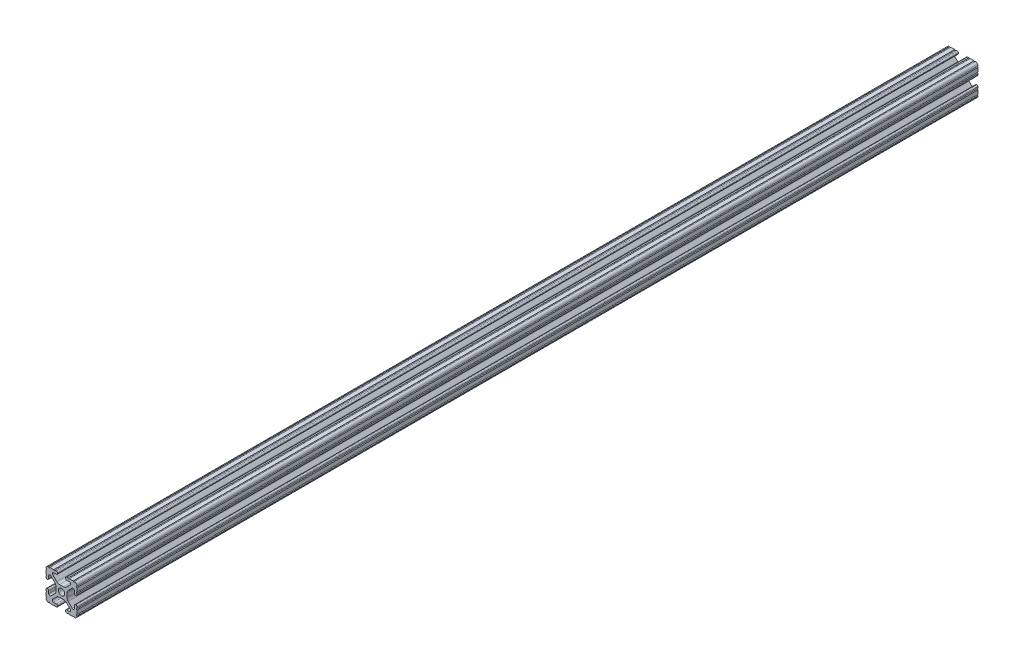
from build123d import *

# Parameters (mm, degrees)
SKETCH1_R           = 2.6035
BOSS_EXTRUDE1_DEPTH = 368.3


with BuildPart() as part:
    # Sketch1 → Boss-Extrude1 (new body, symmetric)
    with BuildSketch(Plane.XY):
        with BuildLine():
            Line((-7.179650497, -8.645192506), (-3.952270251, -5.423690499))
            ThreePointArc((-3.952270251, -5.423690499), (-2.922936451, -4.736929036), (-1.709253557, -4.4958))
            Line((-1.709253557, -4.4958), (1.709253557, -4.4958))
            ThreePointArc((1.709253557, -4.4958), (2.922936451, -4.736929036), (3.952270251, -5.423690499))
            Line((3.952270251, -5.423690499), (7.179650497, -8.645192506))
            ThreePointArc((7.179650497, -8.645192506), (7.41473083, -9.822813117), (6.416408329, -10.4902))
            Line((6.416408329, -10.4902), (4.287512407, -10.4902))
            ThreePointArc((4.287512407, -10.4902), (3.54574862, -10.79744862), (3.2385, -11.539212407))
            Line((3.2385, -11.539212407), (3.2385, -11.650987593))
            ThreePointArc((3.2385, -11.650987593), (3.54574862, -12.39275138), (4.287512407, -12.7))
            Line((4.287512407, -12.7), (5.317126718, -12.7))
            ThreePointArc((5.317126718, -12.7), (5.825126718, -12.192), (6.333126718, -12.7))
            Line((6.333126718, -12.7), (9.550443118, -12.7))
            ThreePointArc((9.550443118, -12.7), (10.058366869, -12.192000006), (10.566443095, -12.699847501))
            ThreePointArc((10.566443095, -12.699847501), (12.082537762, -12.08250727), (12.699846982, -10.566399977))
            ThreePointArc((12.699846982, -10.566399977), (12.192000006, -10.058323491), (12.7, -9.5504))
            Line((12.7, -9.5504), (12.7, -6.3330836))
            ThreePointArc((12.7, -6.3330836), (12.192, -5.8250836), (12.7, -5.3170836))
            Line((12.7, -5.3170836), (12.7, -4.287469289))
            ThreePointArc((12.7, -4.287469289), (12.39275138, -3.545705502), (11.650987593, -3.238456882))
            Line((11.650987593, -3.238456882), (11.539212407, -3.238456882))
            ThreePointArc((11.539212407, -3.238456882), (10.79744862, -3.545705502), (10.4902, -4.287469289))
            Line((10.4902, -4.287469289), (10.4902, -6.402089023))
            ThreePointArc((10.4902, -6.402089023), (9.856505071, -7.351067942), (8.737131347, -7.129408934))
            Line((8.737131347, -7.129408934), (5.441005833, -3.840816462))
            ThreePointArc((5.441005833, -3.840816462), (4.750877967, -2.809883091), (4.5085, -1.593185507))
            Line((4.5085, -1.593185507), (4.5085, 1.593185507))
            ThreePointArc((4.5085, 1.593185507), (4.750877967, 2.809883091), (5.441005833, 3.840816462))
            Line((5.441005833, 3.840816462), (8.737131347, 7.129408934))
            ThreePointArc((8.737131347, 7.129408934), (9.856505071, 7.351067942), (10.4902, 6.402089023))
            Line((10.4902, 6.402089023), (10.4902, 4.287469289))
            ThreePointArc((10.4902, 4.287469289), (10.79744862, 3.545705502), (11.539212407, 3.238456882))
            Line((11.539212407, 3.238456882), (11.650987593, 3.238456882))
            ThreePointArc((11.650987593, 3.238456882), (12.39275138, 3.545705502), (12.7, 4.287469289))
            Line((12.7, 4.287469289), (12.7, 5.3170836))
            ThreePointArc((12.7, 5.3170836), (12.192, 5.8250836), (12.7, 6.3330836))
            Line((12.7, 6.3330836), (12.7, 9.5504))
            ThreePointArc((12.7, 9.5504), (12.192000006, 10.058323491), (12.699846982, 10.566399977))
            ThreePointArc((12.699846982, 10.566399977), (12.082537762, 12.08250727), (10.566443095, 12.699847501))
            ThreePointArc((10.566443095, 12.699847501), (10.058366869, 12.192000006), (9.550443118, 12.7))
            Line((9.550443118, 12.7), (6.333126718, 12.7))
            ThreePointArc((6.333126718, 12.7), (5.825126718, 12.192), (5.317126718, 12.7))
            Line((5.317126718, 12.7), (4.287512407, 12.7))
            ThreePointArc((4.287512407, 12.7), (3.54574862, 12.39275138), (3.2385, 11.650987593))
            Line((3.2385, 11.650987593), (3.2385, 11.539212407))
            ThreePointArc((3.2385, 11.539212407), (3.54574862, 10.79744862), (4.287512407, 10.4902))
            Line((4.287512407, 10.4902), (6.476788598, 10.4902))
            ThreePointArc((6.476788598, 10.4902), (7.432222385, 9.85140422), (7.207036008, 8.724370562))
            Line((7.207036008, 8.724370562), (3.898272566, 5.423169045))
            ThreePointArc((3.898272566, 5.423169045), (2.869120213, 4.736787962), (1.655778399, 4.4958))
            Line((1.655778399, 4.4958), (-1.655778399, 4.4958))
            ThreePointArc((-1.655778399, 4.4958), (-2.869120213, 4.736787962), (-3.898272566, 5.423169045))
            Line((-3.898272566, 5.423169045), (-7.207036008, 8.724370562))
            ThreePointArc((-7.207036008, 8.724370562), (-7.432222385, 9.85140422), (-6.476788598, 10.4902))
            Line((-6.476788598, 10.4902), (-4.287512407, 10.4902))
            ThreePointArc((-4.287512407, 10.4902), (-3.54574862, 10.79744862), (-3.2385, 11.539212407))
            Line((-3.2385, 11.539212407), (-3.2385, 11.650987593))
            ThreePointArc((-3.2385, 11.650987593), (-3.54574862, 12.39275138), (-4.287512407, 12.7))
            Line((-4.287512407, 12.7), (-5.317126718, 12.7))
            ThreePointArc((-5.317126718, 12.7), (-5.825126718, 12.192), (-6.333126718, 12.7))
            Line((-6.333126718, 12.7), (-9.550443118, 12.7))
            ThreePointArc((-9.550443118, 12.7), (-10.058366869, 12.192000006), (-10.566443095, 12.699847501))
            ThreePointArc((-10.566443095, 12.699847501), (-12.082537762, 12.08250727), (-12.699846982, 10.566399977))
            ThreePointArc((-12.699846982, 10.566399977), (-12.192000006, 10.058323491), (-12.7, 9.5504))
            Line((-12.7, 9.5504), (-12.7, 6.3330836))
            ThreePointArc((-12.7, 6.3330836), (-12.192, 5.8250836), (-12.7, 5.3170836))
            Line((-12.7, 5.3170836), (-12.7, 4.287469289))
            ThreePointArc((-12.7, 4.287469289), (-12.39275138, 3.545705502), (-11.650987593, 3.238456882))
            Line((-11.650987593, 3.238456882), (-11.539212407, 3.238456882))
            ThreePointArc((-11.539212407, 3.238456882), (-10.79744862, 3.545705502), (-10.4902, 4.287469289))
            Line((-10.4902, 4.287469289), (-10.4902, 6.402089023))
            ThreePointArc((-10.4902, 6.402089023), (-9.856505071, 7.351067942), (-8.737131347, 7.129408934))
            Line((-8.737131347, 7.129408934), (-5.441005833, 3.840816462))
            ThreePointArc((-5.441005833, 3.840816462), (-4.750877967, 2.809883091), (-4.5085, 1.593185507))
            Line((-4.5085, 1.593185507), (-4.5085, -1.593185507))
            ThreePointArc((-4.5085, -1.593185507), (-4.750877967, -2.809883091), (-5.441005833, -3.840816462))
            Line((-5.441005833, -3.840816462), (-8.737131347, -7.129408934))
            ThreePointArc((-8.737131347, -7.129408934), (-9.856505071, -7.351067942), (-10.4902, -6.402089023))
            Line((-10.4902, -6.402089023), (-10.4902, -4.287469289))
            ThreePointArc((-10.4902, -4.287469289), (-10.79744862, -3.545705502), (-11.539212407, -3.238456882))
            Line((-11.539212407, -3.238456882), (-11.650987593, -3.238456882))
            ThreePointArc((-11.650987593, -3.238456882), (-12.39275138, -3.545705502), (-12.7, -4.287469289))
            Line((-12.7, -4.287469289), (-12.7, -5.3170836))
            ThreePointArc((-12.7, -5.3170836), (-12.192, -5.8250836), (-12.7, -6.3330836))
            Line((-12.7, -6.3330836), (-12.7, -9.5504))
            ThreePointArc((-12.7, -9.5504), (-12.192000006, -10.058323491), (-12.699846982, -10.566399977))
            ThreePointArc((-12.699846982, -10.566399977), (-12.082537762, -12.08250727), (-10.566443095, -12.699847501))
            ThreePointArc((-10.566443095, -12.699847501), (-10.058366869, -12.192000006), (-9.550443118, -12.7))
            Line((-9.550443118, -12.7), (-6.333126718, -12.7))
            ThreePointArc((-6.333126718, -12.7), (-5.825126718, -12.192), (-5.317126718, -12.7))
            Line((-5.317126718, -12.7), (-4.287512407, -12.7))
            ThreePointArc((-4.287512407, -12.7), (-3.54574862, -12.39275138), (-3.2385, -11.650987593))
            Line((-3.2385, -11.650987593), (-3.2385, -11.539212407))
            ThreePointArc((-3.2385, -11.539212407), (-3.54574862, -10.79744862), (-4.287512407, -10.4902))
            Line((-4.287512407, -10.4902), (-6.416408329, -10.4902))
            ThreePointArc((-6.416408329, -10.4902), (-7.41473083, -9.822813117), (-7.179650497, -8.645192506))
        make_face()
        Circle(SKETCH1_R, mode=Mode.SUBTRACT)
    extrude(amount=BOSS_EXTRUDE1_DEPTH, both=True)


solid = part.part
